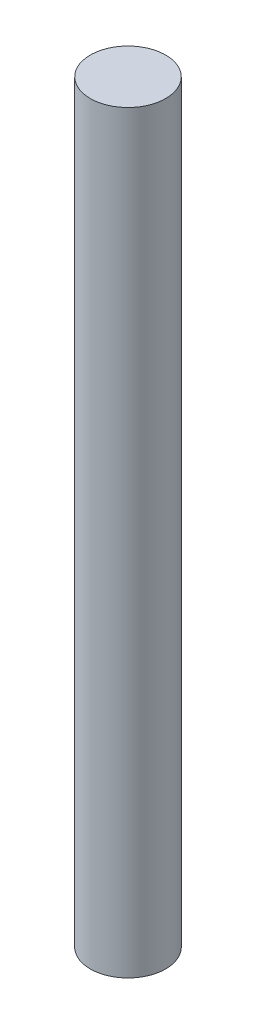
from build123d import *

# Parameters (mm, degrees)
SKETCH_1_R      = 2.5
EXTRUDE_1_DEPTH = 50


with BuildPart() as part:
    # Эскиз1 → Бобышка-Вытянуть1 (new body)
    with BuildSketch(Plane(origin=(0, 0, 0), x_dir=(1, 0, 0), z_dir=(0, 1, 0))):
        with Locations((-3.347826087, 1.923913043)):
            Circle(SKETCH_1_R)
    extrude(amount=EXTRUDE_1_DEPTH)


solid = part.part
